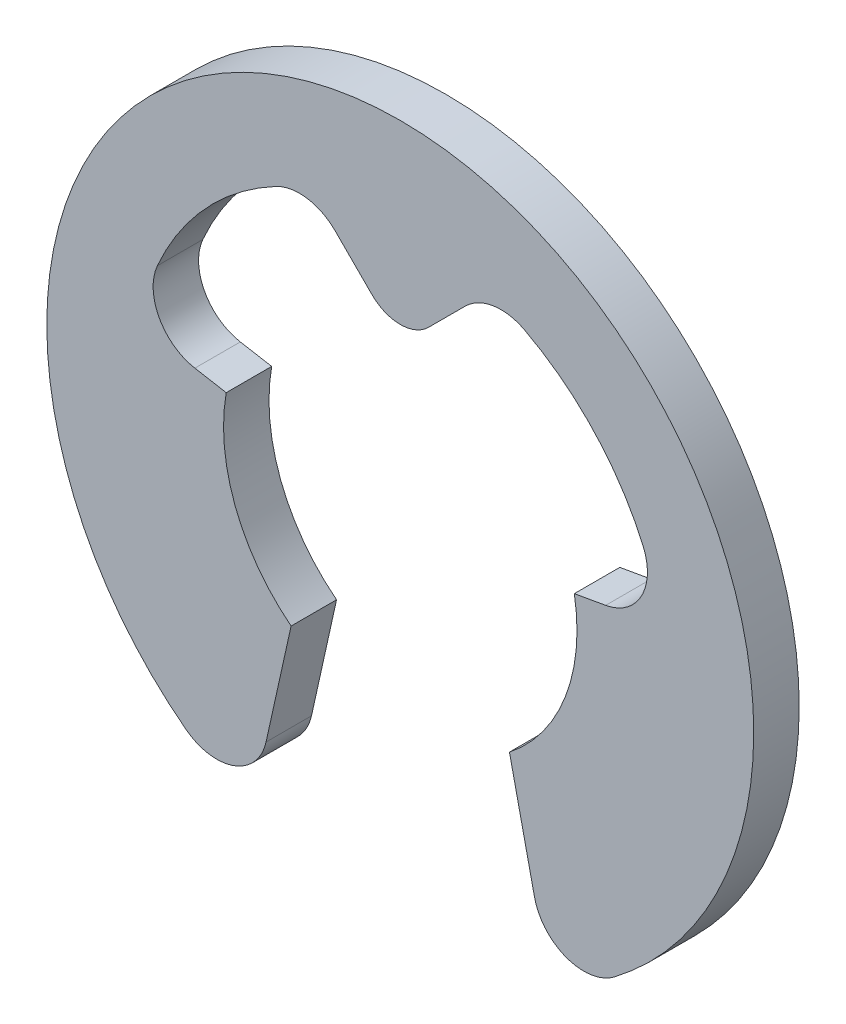
from build123d import *

# Parameters (mm, degrees)
BASE_EXTRUSION_DEPTH = 0.9


with BuildPart() as part:
    # Esquisse1 → Base-Extrusion (new body)
    with BuildSketch(Plane.XY):
        with BuildLine():
            Line((0.560856352, 3.732314307), (1.28816612, 4.459624076))
            ThreePointArc((1.28816612, 4.459624076), (1.847465963, 4.741533528), (2.464748878, 4.635462541))
            ThreePointArc((2.464748878, 4.635462541), (3.851811763, 3.567358427), (4.810575561, 2.102584785))
            ThreePointArc((4.810575561, 2.102584785), (4.775615855, 1.229610596), (4.067923631, 0.717284692))
            Line((4.067923631, 0.717284692), (3.446827136, 0.607768622))
            ThreePointArc((3.446827136, 0.607768622), (3.26917516, -1.24999751), (2.16204859, -2.752370959))
            Line((2.16204859, -2.752370959), (2.658201428, -4.990371787))
            ThreePointArc((2.658201428, -4.990371787), (3.290696787, -5.712974831), (4.240247008, -5.569587535))
            ThreePointArc((4.240247008, -5.569587535), (0, 7), (-4.240247008, -5.569587535))
            ThreePointArc((-4.240247008, -5.569587535), (-3.290696787, -5.712974831), (-2.658201428, -4.990371787))
            Line((-2.658201428, -4.990371787), (-2.16204859, -2.752370959))
            ThreePointArc((-2.16204859, -2.752370959), (-3.26917516, -1.24999751), (-3.446827136, 0.607768622))
            Line((-3.446827136, 0.607768622), (-4.067923631, 0.717284692))
            ThreePointArc((-4.067923631, 0.717284692), (-4.775615855, 1.229610596), (-4.810575561, 2.102584785))
            ThreePointArc((-4.810575561, 2.102584785), (-3.851811763, 3.567358427), (-2.464748878, 4.635462541))
            ThreePointArc((-2.464748878, 4.635462541), (-1.847465963, 4.741533528), (-1.28816612, 4.459624076))
            Line((-1.28816612, 4.459624076), (-0.560856352, 3.732314307))
            ThreePointArc((-0.560856352, 3.732314307), (0, 3.5), (0.560856352, 3.732314307))
        make_face()
    extrude(amount=BASE_EXTRUSION_DEPTH)


solid = part.part
